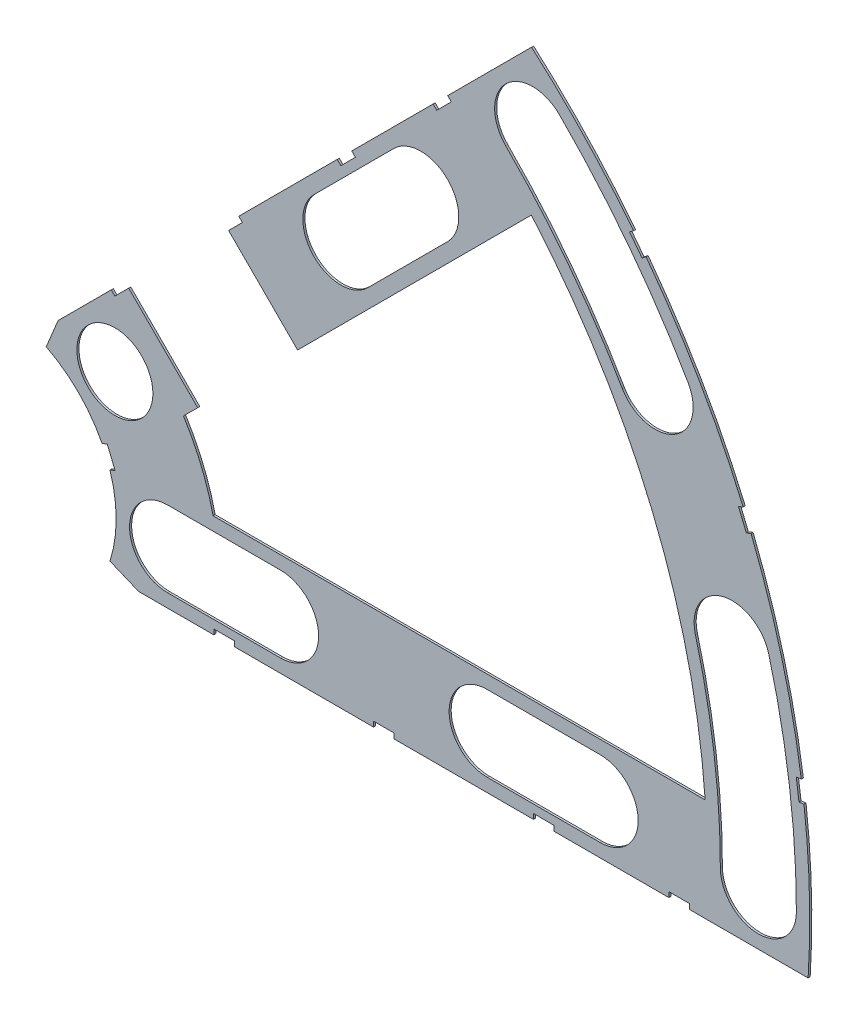
from build123d import *

# Parameters (mm, degrees)
BOSS_EXTRUDE1_DEPTH = 0.254
SKETCH2_R           = 4.699
CUT_EXTRUDE1_DEPTH  = 1.254
SKETCH3_W           = 2.54
SKETCH3_H           = 0.635
CUT_EXTRUDE2_DEPTH  = 1.254
CUT_EXTRUDE4_DEPTH  = 1.254
CUT_EXTRUDE5_DEPTH  = 1.254


with BuildPart() as part:
    # Sketch1 → Boss-Extrude1 (new body)
    with BuildSketch(Plane.XY):
        with BuildLine():
            Line((67.21146711, 76.191723231), (8.696654013, 17.676910134))
            Line((8.696654013, 17.676910134), (7.228954972, 14.133571205))
            ThreePointArc((7.228954972, 14.133571205), (14.666587579, 6.075099489), (15.105587123, -4.88230096))
            Line((15.105587123, -4.88230096), (18.648926052, -6.35))
            Line((18.648926052, -6.35), (101.401368334, -6.35))
            ThreePointArc((101.401368334, -6.35), (93.866160503, 38.880636728), (67.21146711, 76.191723231))
        make_face()
        with BuildLine():
            Line((88.672924278, 6.35), (27.86051193, 6.35))
            ThreePointArc((27.86051193, 6.35), (26.399857642, 10.93517908), (24.190484974, 15.210228852))
            Line((24.190484974, 15.210228852), (67.191354125, 58.211098004))
            ThreePointArc((67.191354125, 58.211098004), (82.13289044, 34.020557137), (88.672924278, 6.35))
        make_face(mode=Mode.SUBTRACT)
    extrude(amount=BOSS_EXTRUDE1_DEPTH)

    # Sketch2 → Cut-Extrude1 (cut, through all)
    with BuildSketch(Plane.XY.offset(0.254)):
        with Locations((22.225, 0)):
            Circle(SKETCH2_R)
        with Locations((36.195, 0)):
            Circle(SKETCH2_R)
        with Locations((61.722, 0)):
            Circle(SKETCH2_R)
        with Locations((75.692, 0)):
            Circle(SKETCH2_R)
        with Locations((95.25, 0)):
            Circle(SKETCH2_R)
        with Locations((15.715448212, 15.715448212)):
            Circle(SKETCH2_R)
        with Locations((25.593729945, 25.593729945)):
            Circle(SKETCH2_R)
        with Locations((43.644044748, 43.644044748)):
            Circle(SKETCH2_R)
        with Locations((53.522326482, 53.522326482)):
            Circle(SKETCH2_R)
        with Locations((92.004434954, 24.652514046)):
            Circle(SKETCH2_R)
        with Locations((82.48891971, 47.625)):
            Circle(SKETCH2_R)
        with Locations((67.351920908, 67.351920908)):
            Circle(SKETCH2_R)
    extrude(amount=-CUT_EXTRUDE1_DEPTH, mode=Mode.SUBTRACT)

    # Sketch3 → Cut-Extrude2 (cut, through all)
    with BuildSketch(Plane.XY.offset(0.254)):
        Polygon((15.266435406, 24.246691527), (17.06248663, 26.042742751), (17.511499436, 25.593729945), (15.715448212, 23.797678721), align=None)
        Polygon((44.991083167, 53.971339288), (43.195031942, 52.175288063), (43.644044748, 51.726275257), (45.440095973, 53.522326482), align=None)
        with Locations((29.21, -6.0325)):
            Rectangle(SKETCH3_W, SKETCH3_H)
        with Locations((68.707, -6.0325)):
            Rectangle(SKETCH3_W, SKETCH3_H)
        Polygon((29.230733674, 38.210989795), (31.026784898, 40.007041019), (31.475797704, 39.558028213), (29.67974648, 37.761976989), align=None)
        Polygon((56.845021246, 65.825277367), (55.048970022, 64.029226143), (55.497982828, 63.580213337), (57.294034052, 65.376264561), align=None)
        with Locations((48.9585, -6.0325)):
            Rectangle(SKETCH3_W, SKETCH3_H)
        with Locations((85.471, -6.0325)):
            Rectangle(SKETCH3_W, SKETCH3_H)
        Polygon((99.935462164, 14.437711971), (100.266998693, 11.919442024), (101.526133667, 12.085210288), (101.194597138, 14.603480236), align=None)
        Polygon((93.765504959, 37.464305742), (94.938831965, 37.950313702), (93.966816047, 40.296967714), (92.793489041, 39.810959755), align=None)
        Polygon((79.327792988, 62.471156422), (80.874047017, 60.456038938), (81.88160576, 61.229165953), (80.33535173, 63.244283437), align=None)
        Polygon((13.593916116, 7.005422516), (14.565932035, 4.658768503), (15.739259041, 5.144776462), (14.767243123, 7.491430475), align=None)
    extrude(amount=-CUT_EXTRUDE2_DEPTH, mode=Mode.SUBTRACT)

    # Sketch6 → Cut-Extrude4 (cut, through all)
    with BuildSketch(Plane.XY.offset(0.254)):
        with BuildLine():
            Line((40.321349984, 46.966739513), (50.199631717, 56.845021246))
            ThreePointArc((50.199631717, 56.845021246), (56.845021246, 56.845021246), (56.845021246, 50.199631717))
            Line((56.845021246, 50.199631717), (46.966739513, 40.321349984))
            ThreePointArc((46.966739513, 40.321349984), (40.321349984, 40.321349984), (40.321349984, 46.966739513))
        make_face()
        with BuildLine():
            Line((22.225, 4.699), (36.195, 4.699))
            ThreePointArc((36.195, 4.699), (40.894, 0), (36.195, -4.699))
            Line((36.195, -4.699), (22.225, -4.699))
            ThreePointArc((22.225, -4.699), (17.526, 0), (22.225, 4.699))
        make_face()
        with BuildLine():
            Line((61.722, 4.699), (75.692, 4.699))
            ThreePointArc((75.692, 4.699), (80.391, 0), (75.692, -4.699))
            Line((75.692, -4.699), (61.722, -4.699))
            ThreePointArc((61.722, -4.699), (57.023, 0), (61.722, 4.699))
        make_face()
        with BuildLine():
            ThreePointArc((99.949, 0), (99.093922449, 13.045962386), (96.543320412, 25.868704739))
            ThreePointArc((96.543320412, 25.868704739), (90.788244261, 29.191399504), (87.465549496, 23.436323353))
            ThreePointArc((87.465549496, 23.436323353), (89.776323642, 11.819277232), (90.551, 0))
            ThreePointArc((90.551, 0), (95.25, -4.699), (99.949, 0))
        make_face()
        with BuildLine():
            ThreePointArc((86.558373083, 49.9745), (79.294873009, 60.845096068), (70.674615673, 70.674615673))
            ThreePointArc((70.674615673, 70.674615673), (64.029226143, 70.674615673), (64.029226143, 64.029226143))
            ThreePointArc((64.029226143, 64.029226143), (71.838938317, 55.123956158), (78.419466338, 45.2755))
            ThreePointArc((78.419466338, 45.2755), (84.83841971, 43.555546628), (86.558373083, 49.9745))
        make_face()
    extrude(amount=-CUT_EXTRUDE4_DEPTH, mode=Mode.SUBTRACT)

    # Sketch5 → Cut-Extrude5 (cut, through all)
    with BuildSketch(Plane.XY.offset(0.254)):
        Polygon((14.278607232, 28.647017026), (26.626459399, 40.994869193), (40.994869193, 26.626459399), (28.647017026, 14.278607233), align=None)
    extrude(amount=-CUT_EXTRUDE5_DEPTH, mode=Mode.SUBTRACT)


solid = part.part
